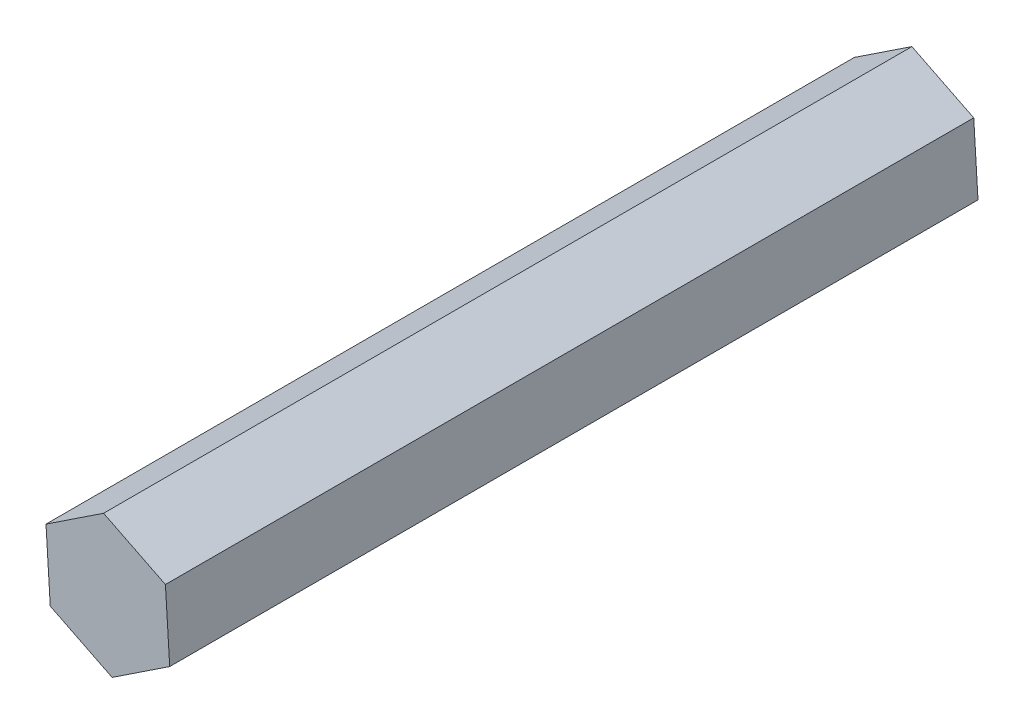
from build123d import *

# Parameters (mm, degrees)
BOSS_EXTRUDE1_DEPTH = 86


with BuildPart() as part:
    # Sketch1 → Boss-Extrude1 (new body)
    with BuildSketch(Plane.XY):
        Polygon((-0.45377191, 7.335979216), (-6.580030318, 3.275011606), (-6.126258407, -4.06096761), (0.45377191, -7.335979216), (6.580030318, -3.275011606), (6.126258407, 4.06096761), align=None)
    extrude(amount=BOSS_EXTRUDE1_DEPTH)


solid = part.part
